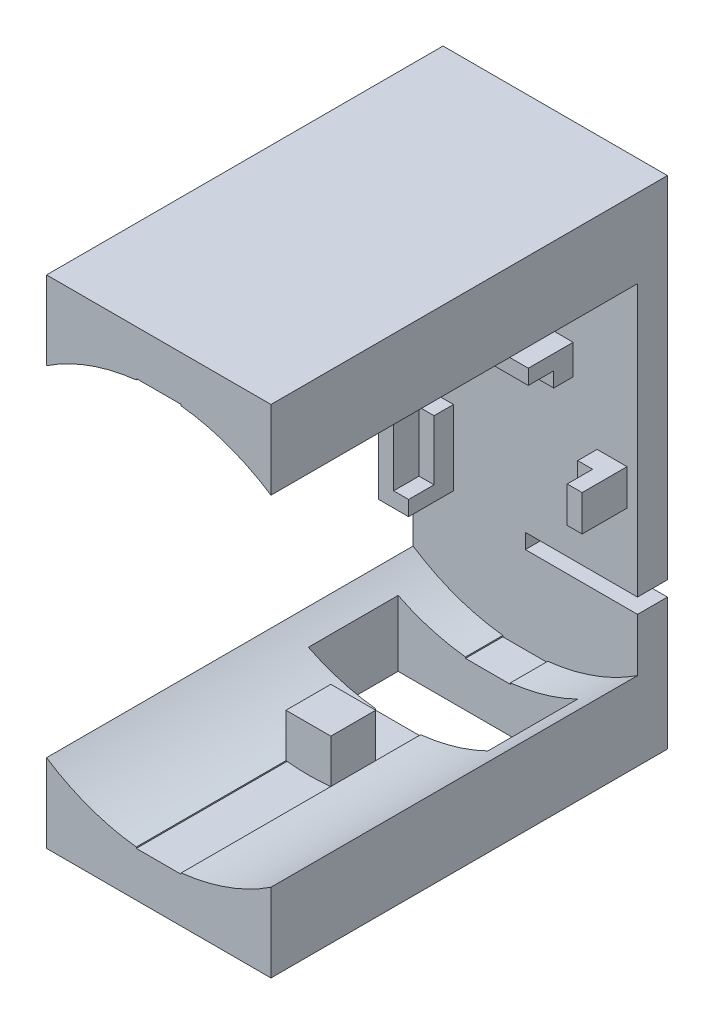
from build123d import *

# Parameters (mm, degrees)
BOSS_EXTRUDE1_DEPTH   = 14.5
BOSS_EXTRUDE1_2_DEPTH = 14.5
BOSS_EXTRUDE1_3_DEPTH = 14.5
BOSS_EXTRUDE1_4_DEPTH = 14.5
SKETCH1_3_W           = 15
SKETCH1_3_H           = 33.2
BOSS_EXTRUDE3_DEPTH   = 2
CUT_EXTRUDE1_DEPTH    = 11.5
BOSS_EXTRUDE4_DEPTH   = 24.5
SKETCH2_W             = 1
SKETCH2_H             = 4
SKETCH2_W_2           = 6.4
SKETCH2_H_2           = 1
SKETCH2_H_3           = 2.4
BOSS_EXTRUDE5_DEPTH   = 1.3
SKETCH2_3_W           = 6.4
SKETCH2_3_H           = 1
SKETCH2_3_W_2         = 1
SKETCH2_3_H_2         = 2.4
BOSS_EXTRUDE6_DEPTH   = 3
SKETCH2_4_W           = 7.5
SKETCH2_4_H           = 1
CUT_EXTRUDE2_DEPTH    = 3
SKETCH3_W             = 12
SKETCH3_H             = 6
CUT_EXTRUDE4_DEPTH    = 5.254957


with BuildPart() as part:
    # Sketch1 → Boss-Extrude1 (new body)
    with BuildSketch(Plane.XY):
        with BuildLine():
            Line((7.5, 16.6), (-7.5, 16.6))
            Line((-7.5, 16.6), (-7.5, 11.34504297))
            ThreePointArc((-7.5, 11.34504297), (-4.629187607, 12.787909215), (-1.5, 13.5170263))
            Line((-1.5, 13.5170263), (-1.5, 13.6))
            Line((-1.5, 13.6), (0, 13.6))
            Line((0, 13.6), (1.5, 13.6))
            Line((1.5, 13.6), (1.5, 13.5170263))
            ThreePointArc((1.5, 13.5170263), (4.629187607, 12.787909215), (7.5, 11.34504297))
            Line((7.5, 11.34504297), (7.5, 16.6))
        make_face()
    extrude(amount=BOSS_EXTRUDE1_DEPTH)



with BuildPart() as body_2:
    # Sketch1 → Boss-Extrude1 2 (new body)
    with BuildSketch(Plane.XY):
        with BuildLine():
            ThreePointArc((0, 13.6), (-0.751146563, 13.579240731), (-1.5, 13.5170263))
            Line((-1.5, 13.5170263), (-1.5, 10.6))
            Line((-1.5, 10.6), (1.5, 10.6))
            Line((1.5, 10.6), (1.5, 13.5170263))
            ThreePointArc((1.5, 13.5170263), (0.751146563, 13.579240731), (0, 13.6))
        make_face()
    extrude(amount=BOSS_EXTRUDE1_2_DEPTH)


with BuildPart() as body_3:
    # Sketch1 → Boss-Extrude1 3 (new body)
    with BuildSketch(Plane.XY):
        with BuildLine():
            Line((-1.5, -10.6), (-1.5, -13.5170263))
            ThreePointArc((-1.5, -13.5170263), (-0.751146563, -13.579240731), (0, -13.6))
            ThreePointArc((0, -13.6), (0.751146563, -13.579240731), (1.5, -13.5170263))
            Line((1.5, -13.5170263), (1.5, -10.6))
            Line((1.5, -10.6), (-1.5, -10.6))
        make_face()
    extrude(amount=BOSS_EXTRUDE1_3_DEPTH)


with BuildPart() as body_4:
    # Sketch1 → Boss-Extrude1 4 (new body)
    with BuildSketch(Plane.XY):
        with BuildLine():
            ThreePointArc((-1.5, -13.5170263), (-4.629187607, -12.787909215), (-7.5, -11.34504297))
            Line((-7.5, -11.34504297), (-7.5, -16.6))
            Line((-7.5, -16.6), (7.5, -16.6))
            Line((7.5, -16.6), (7.5, -11.34504297))
            ThreePointArc((7.5, -11.34504297), (4.629187607, -12.787909215), (1.5, -13.5170263))
            Line((1.5, -13.5170263), (1.5, -13.6))
            Line((1.5, -13.6), (0, -13.6))
            Line((0, -13.6), (-1.5, -13.6))
            Line((-1.5, -13.6), (-1.5, -13.5170263))
        make_face()
    extrude(amount=BOSS_EXTRUDE1_4_DEPTH)


with BuildPart() as part_1:
    add(part.part)

    add(body_4.part)  # Boss-Extrude3 merges body 4
    # Sketch1_3 → Boss-Extrude3 (add)
    with BuildSketch(Plane.XY):
        Rectangle(SKETCH1_3_W, SKETCH1_3_H)
    extrude(amount=-BOSS_EXTRUDE3_DEPTH)

    # Sketch1_5 → Boss-Extrude4 (add)
    with BuildSketch(Plane.XY):
        with BuildLine():
            Line((7.5, 16.6), (-7.5, 16.6))
            Line((-7.5, 16.6), (-7.5, 11.34504297))
            ThreePointArc((-7.5, 11.34504297), (-4.629187607, 12.787909215), (-1.5, 13.5170263))
            Line((-1.5, 13.5170263), (-1.5, 13.6))
            Line((-1.5, 13.6), (0, 13.6))
            Line((0, 13.6), (1.5, 13.6))
            Line((1.5, 13.6), (1.5, 13.5170263))
            ThreePointArc((1.5, 13.5170263), (4.629187607, 12.787909215), (7.5, 11.34504297))
            Line((7.5, 11.34504297), (7.5, 16.6))
        make_face()
        with BuildLine():
            ThreePointArc((-1.5, -13.5170263), (-4.629187607, -12.787909215), (-7.5, -11.34504297))
            Line((-7.5, -11.34504297), (-7.5, -16.6))
            Line((-7.5, -16.6), (7.5, -16.6))
            Line((7.5, -16.6), (7.5, -11.34504297))
            ThreePointArc((7.5, -11.34504297), (4.629187607, -12.787909215), (1.5, -13.5170263))
            Line((1.5, -13.5170263), (1.5, -13.6))
            Line((1.5, -13.6), (0, -13.6))
            Line((0, -13.6), (-1.5, -13.6))
            Line((-1.5, -13.6), (-1.5, -13.5170263))
        make_face()
    extrude(amount=BOSS_EXTRUDE4_DEPTH)

    # Sketch2 → Boss-Extrude5 (add)
    with BuildSketch(Plane.XY):
        with Locations((-5.3, -3.8)):
            Rectangle(SKETCH2_W, SKETCH2_H)
        with Locations((0, 4.3)):
            Rectangle(SKETCH2_W_2, SKETCH2_H_2)
        with Locations((5.3, -0.8)):
            Rectangle(SKETCH2_W, SKETCH2_H_3)
    extrude(amount=BOSS_EXTRUDE5_DEPTH)

    # Sketch2_3 → Boss-Extrude6 (add)
    with BuildSketch(Plane.XY):
        with Locations((0, 5.3)):
            Rectangle(SKETCH2_3_W, SKETCH2_3_H)
        Polygon((-5.8, -1.8), (-6.8, -1.8), (-6.8, -6.8), (-4.8, -6.8), (-4.8, -5.8), (-5.8, -5.8), align=None)
        with Locations((6.3, -0.8)):
            Rectangle(SKETCH2_3_W_2, SKETCH2_3_H_2)
    extrude(amount=BOSS_EXTRUDE6_DEPTH)

    # Sketch2_4 → Cut-Extrude2 (cut, through all)
    with BuildSketch(Plane.XY):
        with Locations((3.75, -7.3)):
            Rectangle(SKETCH2_4_W, SKETCH2_4_H)
    extrude(amount=-CUT_EXTRUDE2_DEPTH, mode=Mode.SUBTRACT)

    # Sketch3 → Cut-Extrude4 (cut)
    with BuildSketch(Plane(origin=(0, -11.34504297, 0), x_dir=(-1, 0, 0), z_dir=(0, -1, 0))):
        with Locations((0, -5.5)):
            Rectangle(SKETCH3_W, SKETCH3_H)
    extrude(amount=CUT_EXTRUDE4_DEPTH, mode=Mode.SUBTRACT)


with BuildPart() as cut_extrude1_tool:
    # Sketch1_4 → Cut-Extrude1 (new body)
    with BuildSketch(Plane.XY):
        with BuildLine():
            Line((-1.5, -10.6), (-1.5, -13.5170263))
            ThreePointArc((-1.5, -13.5170263), (-0.751146563, -13.579240731), (0, -13.6))
            ThreePointArc((0, -13.6), (0.751146563, -13.579240731), (1.5, -13.5170263))
            Line((1.5, -13.5170263), (1.5, -10.6))
            Line((1.5, -10.6), (-1.5, -10.6))
        make_face()
        with BuildLine():
            ThreePointArc((0, 13.6), (-0.751146563, 13.579240731), (-1.5, 13.5170263))
            Line((-1.5, 13.5170263), (-1.5, 10.6))
            Line((-1.5, 10.6), (1.5, 10.6))
            Line((1.5, 10.6), (1.5, 13.5170263))
            ThreePointArc((1.5, 13.5170263), (0.751146563, 13.579240731), (0, 13.6))
        make_face()
    extrude(amount=CUT_EXTRUDE1_DEPTH)


with BuildPart() as body_2_1:
    add(body_2.part)

    # Cut-Extrude1: cut by cut_extrude1_tool
    add(cut_extrude1_tool.part, mode=Mode.SUBTRACT)


with BuildPart() as body_3_1:
    add(body_3.part)

    # Cut-Extrude1: cut by cut_extrude1_tool
    add(cut_extrude1_tool.part, mode=Mode.SUBTRACT)


solid = Compound([part_1.part, body_2_1.part, body_3_1.part])
